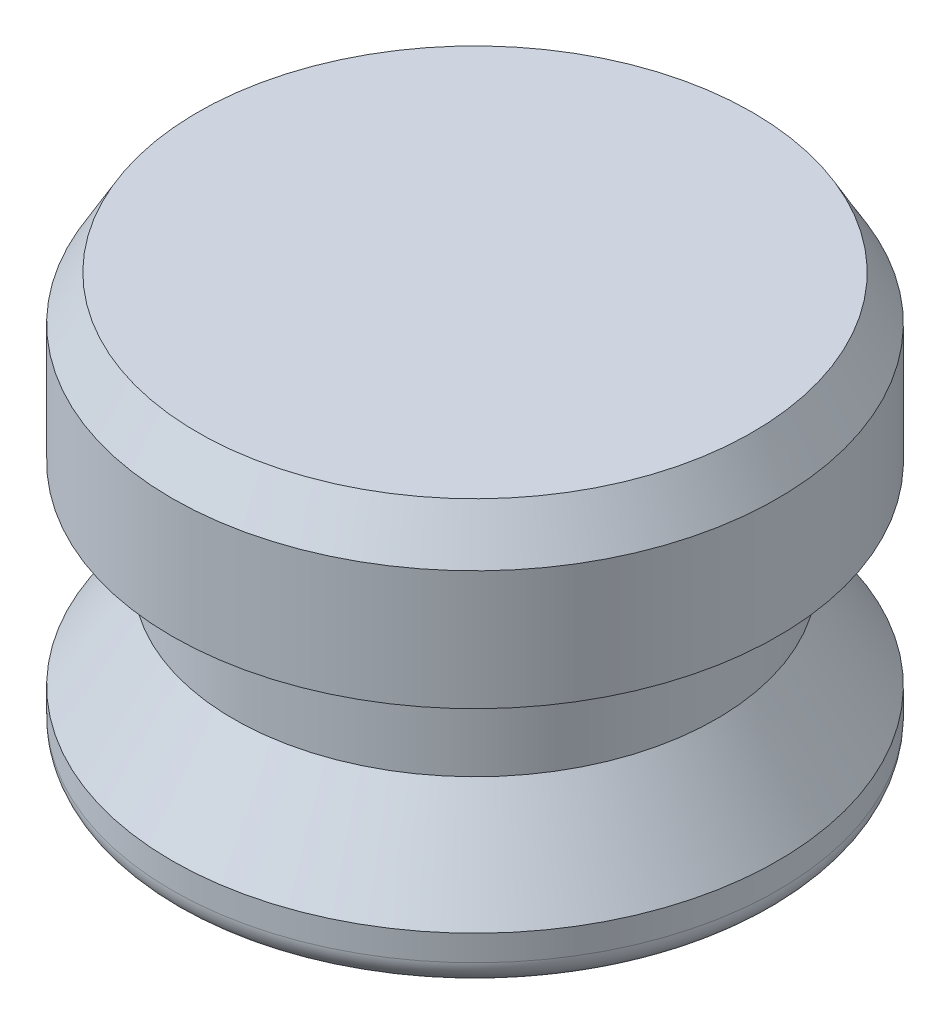
from build123d import *

# Parameters (mm, degrees)
FILLET1_R      = 0.79375
CHAMFER1_SIZE  = 0.79375
CHAMFER1_SIZE2 = 1.374815329


with BuildPart() as part:
    # Sketch1 → Revolve1 (revolve)
    with BuildSketch(Plane.XY):
        Polygon((0, 0), (-9.398, 0), (-9.398, 1.5875), (-7.493, 4.445), (-7.493, 7.62), (-9.398, 7.62), (-9.398, 12.7), (0, 12.7), align=None)
    revolve(axis=Axis((0, 0, 0), (0, 1, 0)))

    # Fillet1
    fillet1_edges = [part.edges().sort_by_distance(p)[0] for p in [
        (9.398, 0, 0),
    ]]
    fillet(fillet1_edges, radius=FILLET1_R)

    # Chamfer1
    chamfer1_edges = [part.edges().sort_by_distance(p)[0] for p in [
        (9.398, 12.7, 0),
    ]]
    chamfer1_side = [part.faces().sort_by_distance(p)[0] for p in [
        (0, 12.7, 0),
    ]]
    chamfer(chamfer1_edges, length=CHAMFER1_SIZE, length2=CHAMFER1_SIZE2, reference=chamfer1_side[0])


solid = part.part
